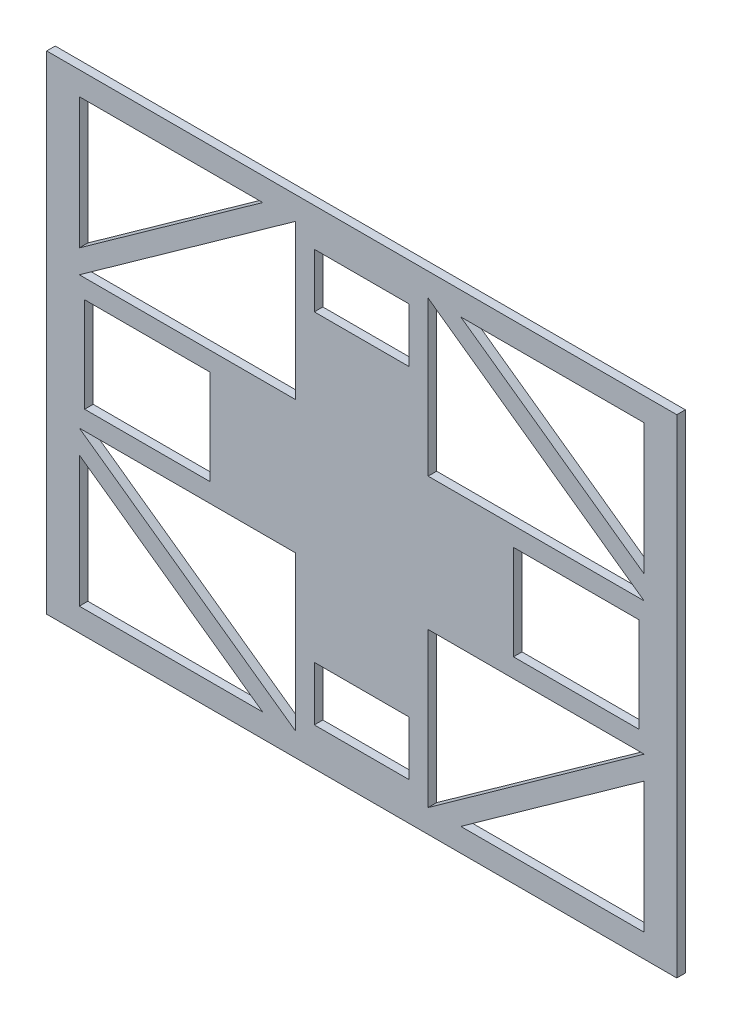
from build123d import *

# Parameters (mm, degrees)
IZIM1_W                     = 50
IZIM1_H                     = 50
IZIM1_H_2                   = 45
IZIM1_W_2                   = 45
Y_KSEKLIK_EKSTR_ZYON2_DEPTH = 4.5
IZIM2_R                     = 3
Y_KSEKLIK_EKSTR_ZYON3_DEPTH = 10
IZIM4_W                     = 15
IZIM4_H                     = 5
IZIM4_W_2                   = 5
IZIM4_H_2                   = 15
Y_KSEKLIK_EKSTR_ZYON5_DEPTH = 10
IZIM5_R                     = 2
KES_EKSTR_ZYON1_DEPTH       = 132.1
IZIM6_R                     = 2
KES_EKSTR_ZYON2_DEPTH       = 169.6


with BuildPart() as part:
    # Çizim1 → Yükseklik-Ekstrüzyon2 (new body)
    with BuildSketch(Plane.XY):
        Polygon((-35, -128.6), (-35, -116.312863708), (-52.209867178, -116.312863708), align=None)
        Polygon((-35, -116.312863708), (-148.890132822, -35), (-148.890132822, -47.287136292), (-52.209867178, -116.312863708), align=None)
        Polygon((-25, -35), (-35, -35), (-35, -116.312863708), (-35, -128.6), (35, -128.6), (35, -116.312863708), (35, -35), (25, -35), (25, -80), (25, -108.6), (-25, -108.6), (-25, -80), align=None)
        Polygon((-148.890132822, -47.287136292), (-166.1, -35), (-166.1, -128.6), (-35, -128.6), (-52.209867178, -116.312863708), (-148.890132822, -116.312863708), align=None)
        Polygon((-148.890132822, -35), (-166.1, -35), (-148.890132822, -47.287136292), align=None)
        Polygon((-35, 25), (-35, 35), (-148.890132822, 35), (-166.1, 35), (-166.1, -35), (-148.890132822, -35), (-35, -35), (-35, -25), (-80, -25), (-146.1, -25), (-146.1, 25), (-80, 25), align=None)
        Polygon((-25, 35), (-35, 35), (-35, 25), (-35, -25), (-35, -35), (-25, -35), (25, -35), (35, -35), (35, -25), (35, 25), (35, 35), (25, 35), align=None)
        Rectangle(IZIM1_W, IZIM1_H, mode=Mode.SUBTRACT)
        with Locations((0, -57.5)):
            Rectangle(IZIM1_W, IZIM1_H_2)
        Rectangle(IZIM1_W, IZIM1_H)
        with Locations((-57.5, 0)):
            Rectangle(IZIM1_W_2, IZIM1_H)
        with Locations((57.5, 0)):
            Rectangle(IZIM1_W_2, IZIM1_H)
        Polygon((148.890132822, 35), (35, 35), (35, 25), (80, 25), (146.1, 25), (146.1, -25), (80, -25), (35, -25), (35, -35), (148.890132822, -35), (166.1, -35), (166.1, 35), align=None)
        Polygon((148.890132822, -47.287136292), (148.890132822, -35), (35, -116.312863708), (52.209867178, -116.312863708), align=None)
        Polygon((148.890132822, -47.287136292), (166.1, -35), (148.890132822, -35), align=None)
        Polygon((166.1, -128.6), (166.1, -35), (148.890132822, -47.287136292), (148.890132822, -116.312863708), (52.209867178, -116.312863708), (35, -128.6), align=None)
        Polygon((52.209867178, -116.312863708), (35, -116.312863708), (35, -128.6), align=None)
        Polygon((52.209867178, 116.312863708), (35, 116.312863708), (148.890132822, 35), (148.890132822, 47.287136292), align=None)
        Polygon((148.890132822, 47.287136292), (148.890132822, 35), (166.1, 35), align=None)
        Polygon((166.1, 128.6), (35, 128.6), (52.209867178, 116.312863708), (148.890132822, 116.312863708), (148.890132822, 47.287136292), (166.1, 35), align=None)
        Polygon((52.209867178, 116.312863708), (35, 128.6), (35, 116.312863708), align=None)
        Polygon((35, 128.6), (-35, 128.6), (-35, 116.312863708), (-35, 35), (-25, 35), (-25, 80), (-25, 108.6), (25, 108.6), (25, 80), (25, 35), (35, 35), (35, 116.312863708), align=None)
        with Locations((0, 57.5)):
            Rectangle(IZIM1_W, IZIM1_H_2)
        Polygon((-35, 116.312863708), (-35, 128.6), (-52.209867178, 116.312863708), align=None)
        Polygon((-35, 116.312863708), (-52.209867178, 116.312863708), (-148.890132822, 47.287136292), (-148.890132822, 35), align=None)
        Polygon((-52.209867178, 116.312863708), (-35, 128.6), (-166.1, 128.6), (-166.1, 35), (-148.890132822, 47.287136292), (-148.890132822, 116.312863708), align=None)
        Polygon((-148.890132822, 35), (-148.890132822, 47.287136292), (-166.1, 35), align=None)
    extrude(amount=-Y_KSEKLIK_EKSTR_ZYON2_DEPTH)

    # Çizim2 → Yükseklik-Ekstrüzyon3 (add)
    with BuildSketch(Plane(origin=(0, 0, -4.5), x_dir=(-1, 0, 0), z_dir=(0, 0, -1))):
        Circle(IZIM2_R)
    extrude(amount=Y_KSEKLIK_EKSTR_ZYON3_DEPTH)

    # Çizim4 → Yükseklik-Ekstrüzyon5 (add)
    with BuildSketch(Plane(origin=(0, 0, -4.5), x_dir=(-1, 0, 0), z_dir=(0, 0, -1))):
        with Locations((-60, 0)):
            Rectangle(IZIM4_W, IZIM4_H)
        with Locations((0, -60)):
            Rectangle(IZIM4_W_2, IZIM4_H_2)
    extrude(amount=Y_KSEKLIK_EKSTR_ZYON5_DEPTH)

    # Çizim5 → Kes-Ekstrüzyon1 (cut, through all)
    with BuildSketch(Plane.XZ.offset(2.5)):
        with Locations((60, -9.5)):
            Circle(IZIM5_R)
        with Locations((60, -18.5)):
            Circle(IZIM5_R)
    extrude(amount=-KES_EKSTR_ZYON1_DEPTH, mode=Mode.SUBTRACT)

    # Çizim6 → Kes-Ekstrüzyon2 (cut, through all)
    with BuildSketch(Plane(origin=(2.5, 0, 0), x_dir=(0, 0, -1), z_dir=(1, 0, 0))):
        with Locations((9.5, -60)):
            Circle(IZIM6_R)
        with Locations((18.5, -60)):
            Circle(IZIM6_R)
    extrude(amount=-KES_EKSTR_ZYON2_DEPTH, mode=Mode.SUBTRACT)


solid = part.part
